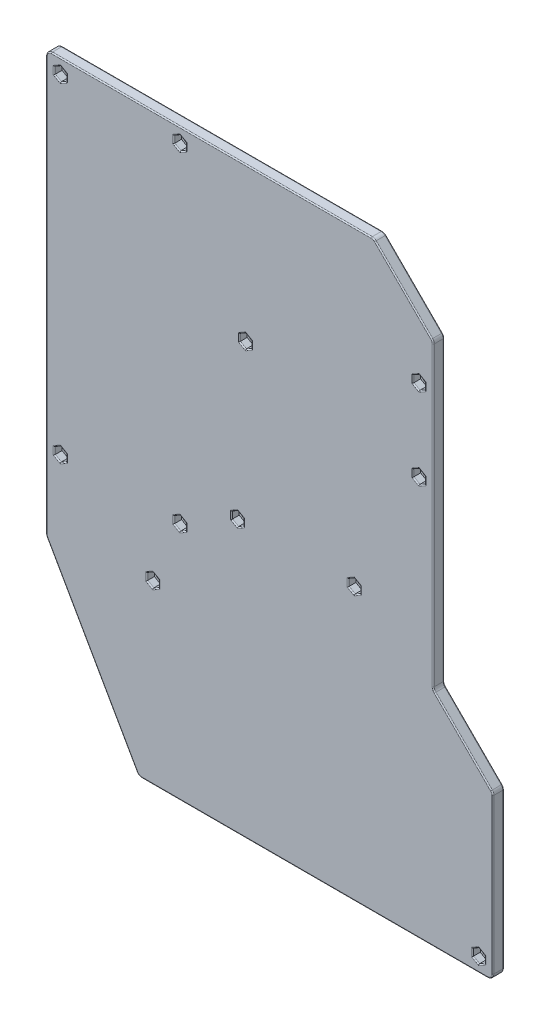
from build123d import *

# Parameters (mm, degrees)
SKETCH1_R           = 1.5
BOSS_EXTRUDE1_DEPTH = 1.5
BOSS_EXTRUDE2_DEPTH = 3.5
FILLET1_R           = 2.5
FILLET2_R           = 0.5


with BuildPart() as part:
    # Sketch1 → Boss-Extrude1 (new body)
    with BuildSketch(Plane.XY):
        Polygon((59.9, 218.7), (32.8, 245.8), (-115.975649276, 245.8), (-115.975649276, 54.65), (-74, -19.15), (87, -19.15), (87, 54.65), (59.9, 81.75), align=None)
        with Locations((53.4, 162.35)):
            Circle(SKETCH1_R, mode=Mode.SUBTRACT)
        with Locations((53.4, 199.35)):
            Circle(SKETCH1_R, mode=Mode.SUBTRACT)
        with Locations((-25.4, 176.25)):
            Circle(SKETCH1_R, mode=Mode.SUBTRACT)
        with Locations((-29, 104.55)):
            Circle(SKETCH1_R, mode=Mode.SUBTRACT)
        with Locations((24, 104.55)):
            Circle(SKETCH1_R, mode=Mode.SUBTRACT)
        with Locations((80.5, -12.65)):
            Circle(SKETCH1_R, mode=Mode.SUBTRACT)
        with Locations((-67.5, 61.15)):
            Circle(SKETCH1_R, mode=Mode.SUBTRACT)
        with Locations((-109.475649276, 89.7)):
            Circle(SKETCH1_R, mode=Mode.SUBTRACT)
        with Locations((-55.2, 89.7)):
            Circle(SKETCH1_R, mode=Mode.SUBTRACT)
        with Locations((-55.2, 239.3)):
            Circle(SKETCH1_R, mode=Mode.SUBTRACT)
        with Locations((-109.475649276, 239.3)):
            Circle(SKETCH1_R, mode=Mode.SUBTRACT)
    extrude(amount=BOSS_EXTRUDE1_DEPTH)

    # Sketch2 → Boss-Extrude2 (add)
    with BuildSketch(Plane.XY.offset(1.5)):
        Polygon((-115.975649276, 245.8), (-115.975649276, 54.65), (-74, -19.15), (87, -19.15), (87, 54.65), (59.9, 81.75), (59.9, 218.7), (32.8, 245.8), align=None)
        Polygon((-109.475649276, 242.475426481), (-112.225649276, 240.88771324), (-112.225649276, 237.71228676), (-109.475649276, 236.124573519), (-106.725649276, 237.71228676), (-106.725649276, 240.88771324), align=None, mode=Mode.SUBTRACT)
        Polygon((-55.2, 242.475426481), (-57.95, 240.88771324), (-57.95, 237.71228676), (-55.2, 236.124573519), (-52.45, 237.71228676), (-52.45, 240.88771324), align=None, mode=Mode.SUBTRACT)
        Polygon((-25.4, 179.425426481), (-28.15, 177.83771324), (-28.15, 174.66228676), (-25.4, 173.074573519), (-22.65, 174.66228676), (-22.65, 177.83771324), align=None, mode=Mode.SUBTRACT)
        Polygon((53.4, 202.525426481), (50.65, 200.93771324), (50.65, 197.76228676), (53.4, 196.174573519), (56.15, 197.76228676), (56.15, 200.93771324), align=None, mode=Mode.SUBTRACT)
        Polygon((53.4, 165.525426481), (50.65, 163.93771324), (50.65, 160.76228676), (53.4, 159.174573519), (56.15, 160.76228676), (56.15, 163.93771324), align=None, mode=Mode.SUBTRACT)
        Polygon((24, 107.725426481), (21.25, 106.13771324), (21.25, 102.96228676), (24, 101.374573519), (26.75, 102.96228676), (26.75, 106.13771324), align=None, mode=Mode.SUBTRACT)
        Polygon((-29, 107.725426481), (-31.75, 106.13771324), (-31.75, 102.96228676), (-29, 101.374573519), (-26.25, 102.96228676), (-26.25, 106.13771324), align=None, mode=Mode.SUBTRACT)
        Polygon((-55.2, 92.875426481), (-57.95, 91.28771324), (-57.95, 88.11228676), (-55.2, 86.524573519), (-52.45, 88.11228676), (-52.45, 91.28771324), align=None, mode=Mode.SUBTRACT)
        Polygon((-109.475649276, 92.875426481), (-112.225649276, 91.28771324), (-112.225649276, 88.11228676), (-109.475649276, 86.524573519), (-106.725649276, 88.11228676), (-106.725649276, 91.28771324), align=None, mode=Mode.SUBTRACT)
        Polygon((-67.5, 64.325426481), (-70.25, 62.73771324), (-70.25, 59.56228676), (-67.5, 57.974573519), (-64.75, 59.56228676), (-64.75, 62.73771324), align=None, mode=Mode.SUBTRACT)
        Polygon((80.5, -9.474573519), (77.75, -11.06228676), (77.75, -14.23771324), (80.5, -15.825426481), (83.25, -14.23771324), (83.25, -11.06228676), align=None, mode=Mode.SUBTRACT)
    extrude(amount=BOSS_EXTRUDE2_DEPTH)

    # Fillet1
    fillet1_edges = [part.edges().sort_by_distance(p)[0] for p in [
        (32.8, 245.8, 2.5),
        (59.9, 218.7, 2.5),
        (59.9, 81.75, 2.5),
        (87, 54.65, 2.5),
        (87, -19.15, 2.5),
        (-74, -19.15, 2.5),
        (-115.975649276, 54.65, 2.5),
        (-115.975649276, 245.8, 2.5),
    ]]
    fillet(fillet1_edges, radius=FILLET1_R)

    # Fillet2
    fillet2_edges = [part.edges().sort_by_distance(p)[0] for p in [
        (-108.100649276, 241.68156986, 5),
        (-110.850649276, 241.68156986, 5),
        (-112.225649276, 239.3, 5),
        (-110.850649276, 236.91843014, 5),
        (-108.100649276, 236.91843014, 5),
        (-106.725649276, 239.3, 5),
        (-53.825, 241.68156986, 5),
        (-56.575, 241.68156986, 5),
        (-57.95, 239.3, 5),
        (-56.575, 236.91843014, 5),
        (-53.825, 236.91843014, 5),
        (-52.45, 239.3, 5),
        (-24.025, 178.63156986, 5),
        (-26.775, 178.63156986, 5),
        (-28.15, 176.25, 5),
        (-26.775, 173.86843014, 5),
        (-24.025, 173.86843014, 5),
        (-22.65, 176.25, 5),
        (54.775, 201.73156986, 5),
        (52.025, 201.73156986, 5),
        (50.65, 199.35, 5),
        (52.025, 196.96843014, 5),
        (54.775, 196.96843014, 5),
        (56.15, 199.35, 5),
        (54.775, 164.73156986, 5),
        (52.025, 164.73156986, 5),
        (50.65, 162.35, 5),
        (52.025, 159.96843014, 5),
        (54.775, 159.96843014, 5),
        (56.15, 162.35, 5),
        (25.375, 106.93156986, 5),
        (22.625, 106.93156986, 5),
        (21.25, 104.55, 5),
        (22.625, 102.16843014, 5),
        (25.375, 102.16843014, 5),
        (26.75, 104.55, 5),
        (-27.625, 106.93156986, 5),
        (-30.375, 106.93156986, 5),
        (-31.75, 104.55, 5),
        (-30.375, 102.16843014, 5),
        (-27.625, 102.16843014, 5),
        (-26.25, 104.55, 5),
        (-53.825, 92.08156986, 5),
        (-56.575, 92.08156986, 5),
        (-57.95, 89.7, 5),
        (-56.575, 87.31843014, 5),
        (-53.825, 87.31843014, 5),
        (-52.45, 89.7, 5),
        (-108.100649276, 92.08156986, 5),
        (-110.850649276, 92.08156986, 5),
        (-112.225649276, 89.7, 5),
        (-110.850649276, 87.31843014, 5),
        (-108.100649276, 87.31843014, 5),
        (-106.725649276, 89.7, 5),
        (-66.125, 63.53156986, 5),
        (-68.875, 63.53156986, 5),
        (-70.25, 61.15, 5),
        (-68.875, 58.76843014, 5),
        (-66.125, 58.76843014, 5),
        (-64.75, 61.15, 5),
        (81.875, -10.26843014, 5),
        (79.125, -10.26843014, 5),
        (77.75, -12.65, 5),
        (79.125, -15.03156986, 5),
        (81.875, -15.03156986, 5),
        (83.25, -12.65, 5),
        (51.9, 162.35, 0),
        (51.9, 162.35, 1.5),
        (51.9, 199.35, 0),
        (51.9, 199.35, 1.5),
        (46.35, 232.25, 0),
        (46.35, 232.25, 5),
        (-40.855591591, 245.8, 0),
        (59.9, 150.225, 0),
        (73.45, 68.2, 0),
        (87, 18.482233047, 0),
        (5.977076877, -19.15, 0),
        (-95.183834582, 18.094617276, 0),
        (-115.975649276, 149.305616331, 0),
        (-115.243416229, 245.067766953, 0),
        (-115.892539536, 54.67198195, 0),
        (-73.802827224, -18.811018005, 0),
        (86.267766953, -18.417766953, 0),
        (86.809698831, 54.571174675, 0),
        (32.721174675, 245.609698831, 0),
        (59.709698831, 218.621174675, 0),
        (59.9, 150.225, 5),
        (-40.855591591, 245.8, 5),
        (-115.975649276, 149.305616331, 5),
        (-95.183834582, 18.094617276, 5),
        (5.977076877, -19.15, 5),
        (87, 18.482233047, 5),
        (73.45, 68.2, 5),
        (-115.243416229, 245.067766953, 5),
        (-115.892539536, 54.67198195, 5),
        (-73.802827224, -18.811018005, 5),
        (86.267766953, -18.417766953, 5),
        (86.809698831, 54.571174675, 5),
        (32.721174675, 245.609698831, 5),
        (59.709698831, 218.621174675, 5),
        (-26.9, 176.25, 0),
        (-26.9, 176.25, 1.5),
        (60.090301169, 81.828825325, 0),
        (60.090301169, 81.828825325, 5),
        (-30.5, 104.55, 0),
        (-30.5, 104.55, 1.5),
        (22.5, 104.55, 0),
        (22.5, 104.55, 1.5),
        (79, -12.65, 0),
        (79, -12.65, 1.5),
        (-69, 61.15, 0),
        (-69, 61.15, 1.5),
        (-110.975649276, 89.7, 0),
        (-110.975649276, 89.7, 1.5),
        (-56.7, 89.7, 0),
        (-56.7, 89.7, 1.5),
        (-56.7, 239.3, 0),
        (-56.7, 239.3, 1.5),
        (-110.975649276, 239.3, 0),
        (-110.975649276, 239.3, 1.5),
    ]]
    fillet(fillet2_edges, radius=FILLET2_R)


solid = part.part
